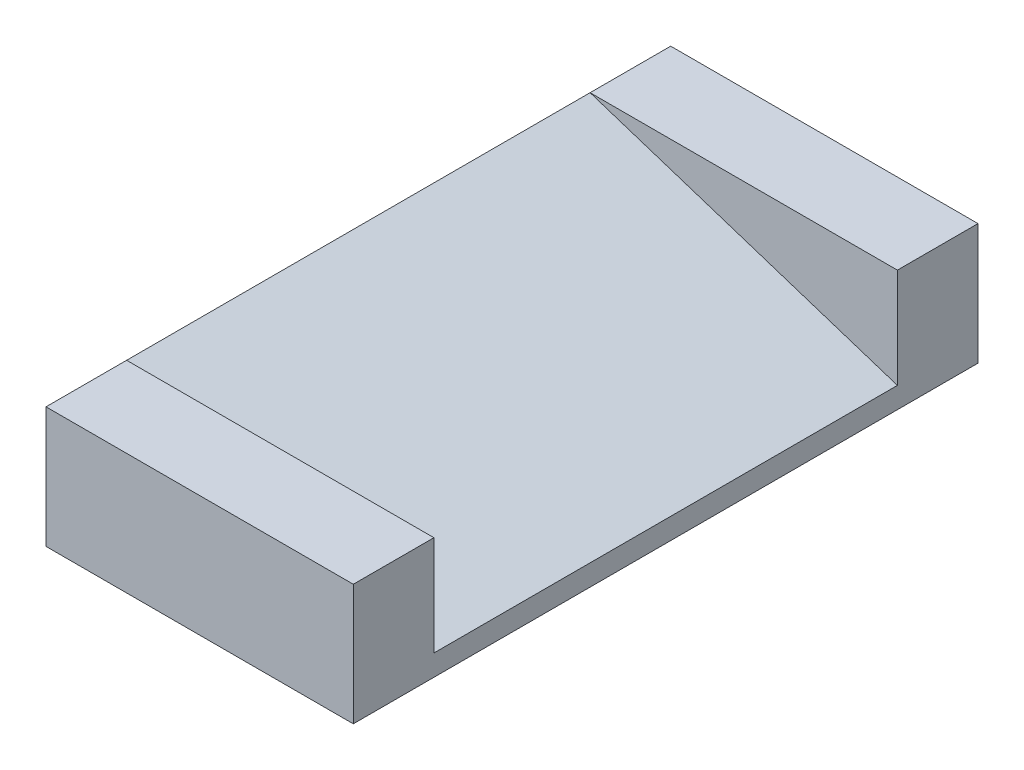
from build123d import *

# Parameters (mm, degrees)
SKETCH1_W           = 30.5
SKETCH1_H           = 62
BOSS_EXTRUDE1_DEPTH = 12
CUT_EXTRUDE1_START  = -46
CUT_EXTRUDE1_DEPTH  = 46


with BuildPart() as part:
    # Sketch1 → Boss-Extrude1 (new body)
    with BuildSketch(Plane(origin=(0, 0, 0), x_dir=(1, 0, 0), z_dir=(0, 1, 0))):
        Rectangle(SKETCH1_W, SKETCH1_H)
    extrude(amount=BOSS_EXTRUDE1_DEPTH)

    # Sketch2 → Cut-Extrude1 (cut)
    with BuildSketch(Plane(origin=(0, 0, -23), x_dir=(-1, 0, 0), z_dir=(0, 0, -1)).offset(CUT_EXTRUDE1_START)):
        Polygon((-15.25, 12), (15.25, 12), (-15.25, 2.089949265), align=None)
    extrude(amount=CUT_EXTRUDE1_DEPTH, mode=Mode.SUBTRACT)


solid = part.part
